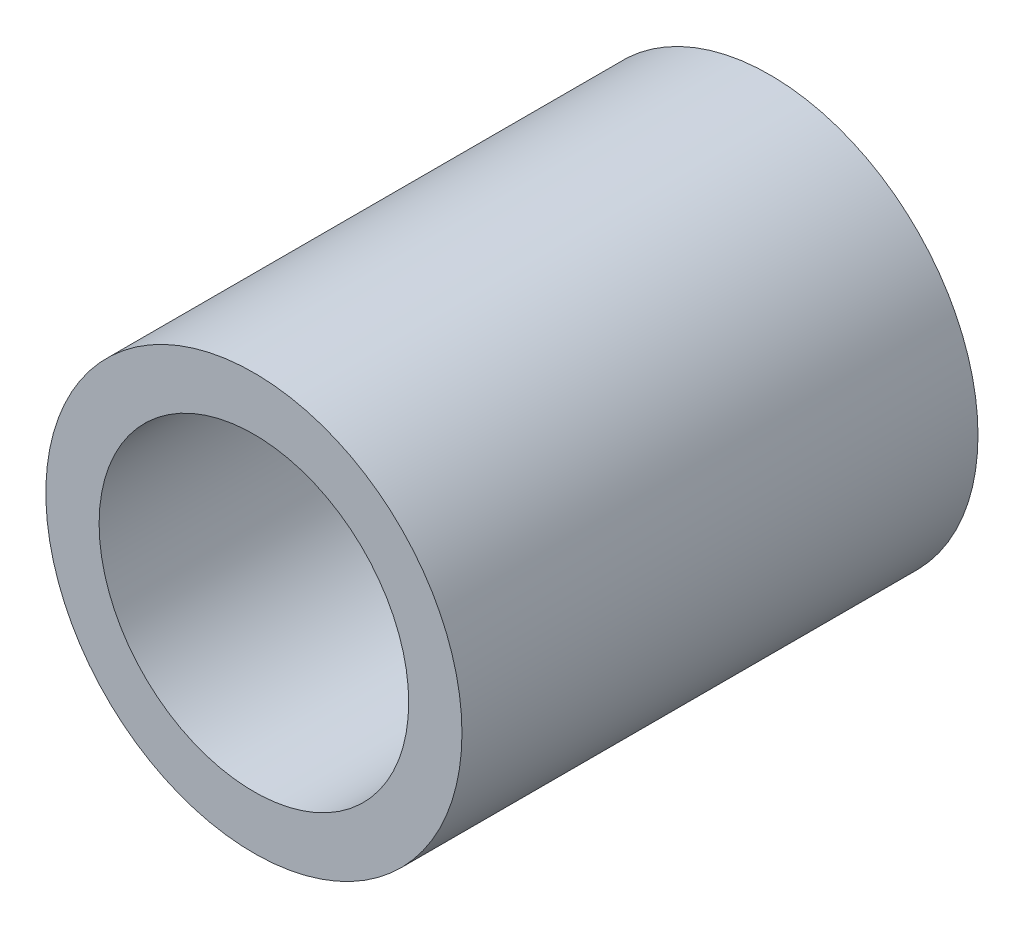
from build123d import *

# Parameters (mm, degrees)
SKETCH5_R           = 3.2004
SKETCH5_R_2         = 2.38125
BOSS_EXTRUDE1_DEPTH = 3.96875


with BuildPart() as part:
    # Sketch5 → Boss-Extrude1 (new, symmetric)
    with BuildSketch(Plane.XY):
        Circle(SKETCH5_R)
        Circle(SKETCH5_R_2, mode=Mode.SUBTRACT)
    extrude(amount=BOSS_EXTRUDE1_DEPTH, both=True)


solid = part.part
